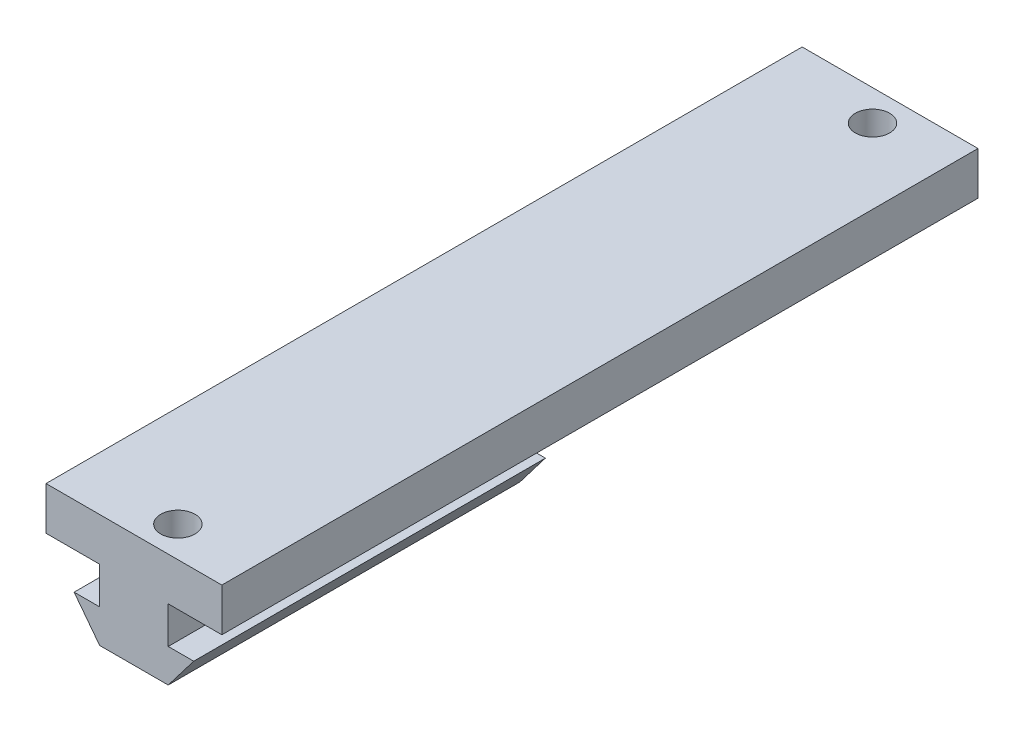
from build123d import *

# Parameters (mm, degrees)
SKETCH1_W           = 20
SKETCH1_H           = 86
BOSS_EXTRUDE1_DEPTH = 4.9
BOSS_EXTRUDE4_DEPTH = 40
SKETCH2_R           = 1.95
CUT_EXTRUDE1_DEPTH  = 6


with BuildPart() as part:
    # Sketch1 → Boss-Extrude1 (new body)
    with BuildSketch(Plane(origin=(0, 0, 0), x_dir=(1, 0, 0), z_dir=(0, 1, 0))):
        Rectangle(SKETCH1_W, SKETCH1_H)
    extrude(amount=BOSS_EXTRUDE1_DEPTH)

    # Sketch4 → Boss-Extrude4 (add)
    with BuildSketch(Plane.XY.offset(43)):
        Polygon((-3.9, 0), (-3.9, -4.2), (-6.8, -4.2), (-3.9, -8), (3.9, -8), (6.8, -4.2), (3.9, -4.2), (3.9, 0), align=None)
    extrude(amount=-BOSS_EXTRUDE4_DEPTH)

    # Sketch2 → Cut-Extrude1 (cut)
    with BuildSketch(Plane(origin=(0, 4.9, 0), x_dir=(1, 0, 0), z_dir=(0, 1, 0))):
        with Locations((1.5, -39.5)):
            Circle(SKETCH2_R)
        with Locations((1.5, 39.5)):
            Circle(SKETCH2_R)
    extrude(amount=-CUT_EXTRUDE1_DEPTH, mode=Mode.SUBTRACT)


solid = part.part
